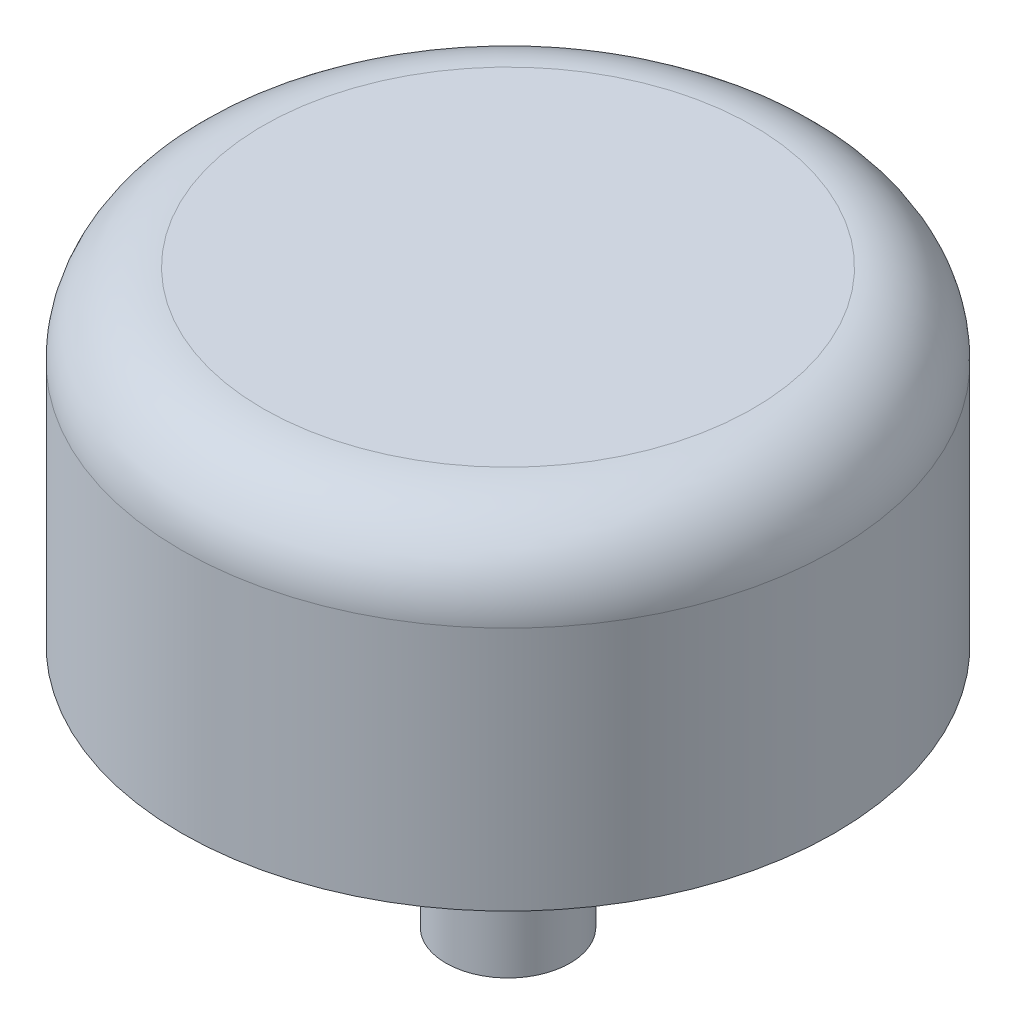
from build123d import *


with BuildPart() as part:
    # Sketch1 → Revolve1 (revolve)
    with BuildSketch(Plane.XY):
        with BuildLine():
            Line((0, -9.525), (-2.413, -9.525))
            Line((-2.413, -9.525), (-2.413, 0))
            Line((-2.413, 0), (-12.7, 0))
            Line((-12.7, 0), (-12.7, 9.525))
            ThreePointArc((-12.7, 9.525), (-11.77006403, 11.77006403), (-9.525, 12.7))
            Line((-9.525, 12.7), (0, 12.7))
            Line((0, 12.7), (0, -9.525))
        make_face()
    revolve(axis=Axis((0, 52.5, 0), (0, -1, 0)))


solid = part.part
